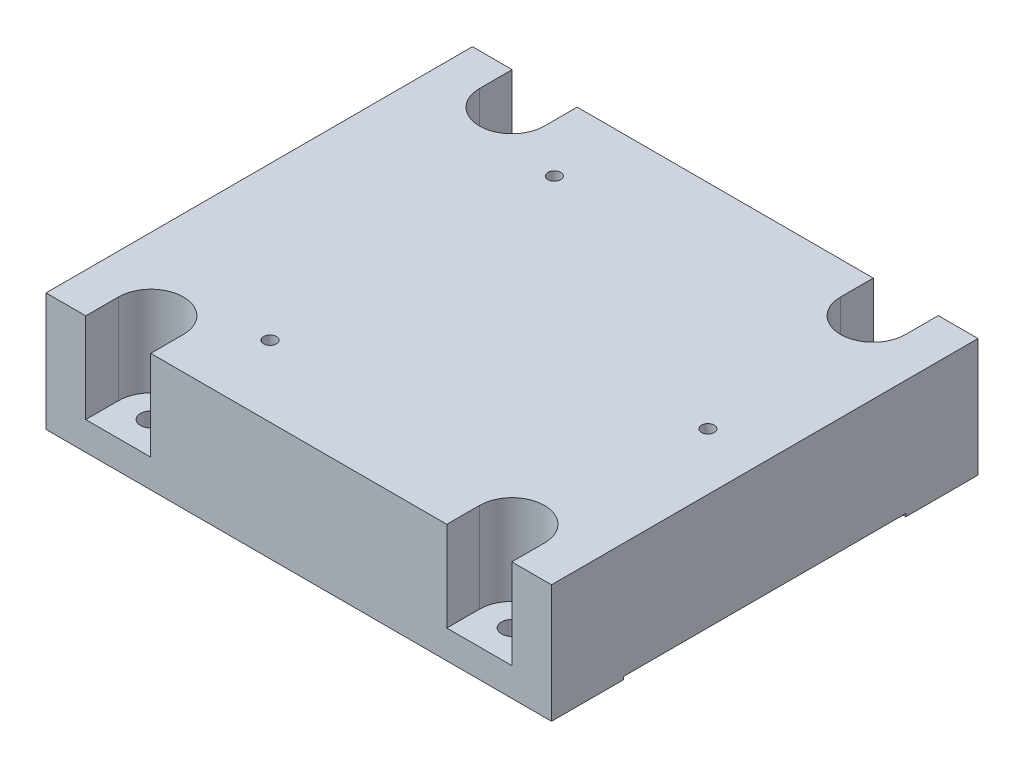
from build123d import *

# Parameters (mm, degrees)
SKETCH1_W                                           = 177.8
SKETCH1_H                                           = 150
BOSS_EXTRUDE1_DEPTH                                 = 41.6
SKETCH2_R                                           = 3.683
CUT_EXTRUDE1_DEPTH                                  = 42.6
CUT_EXTRUDE2_DEPTH                                  = 31.6
CBORE_FOR_M4_HEX_SOCKET_HEAD_CAP_SCREW1_D           = 4.5
CBORE_FOR_M4_HEX_SOCKET_HEAD_CAP_SCREW1_CBORE_D     = 8
CBORE_FOR_M4_HEX_SOCKET_HEAD_CAP_SCREW1_CBORE_DEPTH = 32.6
SKETCH9_W                                           = 177.8
SKETCH9_H                                           = 99.2
CUT_EXTRUDE4_DEPTH                                  = 1


with BuildPart() as part:
    # Sketch1 → Boss-Extrude1 (new body)
    with BuildSketch(Plane(origin=(0, 0, 0), x_dir=(1, 0, 0), z_dir=(0, 1, 0))):
        Rectangle(SKETCH1_W, SKETCH1_H)
    extrude(amount=BOSS_EXTRUDE1_DEPTH)

    # Sketch2 → Cut-Extrude1 (cut, through all)
    with BuildSketch(Plane(origin=(0, 41.6, 0), x_dir=(1, 0, 0), z_dir=(0, 1, 0))):
        with Locations(Location((63.5, -63.5, 0), (0, 0, 270))):  # turned: the seam where the file's is
            Circle(SKETCH2_R)
        with Locations(Location((-63.5, -63.5, 0), (0, 0, 270))):  # turned: the seam where the file's is
            Circle(SKETCH2_R)
    cut_extrude1 = extrude(amount=-CUT_EXTRUDE1_DEPTH, mode=Mode.SUBTRACT)

    # Sketch3 → Cut-Extrude2 (cut)
    with BuildSketch(Plane(origin=(0, 41.6, 0), x_dir=(1, 0, 0), z_dir=(0, 1, 0))):
        with BuildLine():
            Line((-74.93, -63.5), (-74.93, -75))
            Line((-74.93, -75), (-52.07, -75))
            Line((-52.07, -75), (-52.07, -63.5))
            ThreePointArc((-52.07, -63.5), (-63.5, -52.07), (-74.93, -63.5))
        make_face()
        with BuildLine():
            Line((52.07, -63.5), (52.07, -75))
            Line((52.07, -75), (74.93, -75))
            Line((74.93, -75), (74.93, -63.5))
            ThreePointArc((74.93, -63.5), (63.5, -52.07), (52.07, -63.5))
        make_face()
    cut_extrude2 = extrude(amount=-CUT_EXTRUDE2_DEPTH, mode=Mode.SUBTRACT)

    # Mirror1: Cut-Extrude1, Cut-Extrude2 across plane
    add(cut_extrude1.mirror(Plane(origin=(0, 0, 0), x_dir=(1, 0, 0), z_dir=(0, 0, -1))), mode=Mode.SUBTRACT)
    add(cut_extrude2.mirror(Plane(origin=(0, 0, 0), x_dir=(1, 0, 0), z_dir=(0, 0, -1))), mode=Mode.SUBTRACT)

    # CBORE for M4 Hex Socket Head Cap Screw1 (through all)
    with Locations(Plane.XZ):
        with Locations((68.9, 0), (-35.089800026, 50), (-35.089800026, -50)):
            CounterBoreHole(CBORE_FOR_M4_HEX_SOCKET_HEAD_CAP_SCREW1_D / 2, CBORE_FOR_M4_HEX_SOCKET_HEAD_CAP_SCREW1_CBORE_D / 2, CBORE_FOR_M4_HEX_SOCKET_HEAD_CAP_SCREW1_CBORE_DEPTH)

    # Sketch9 → Cut-Extrude4 (cut)
    with BuildSketch(Plane.XZ):
        Rectangle(SKETCH9_W, SKETCH9_H)
    extrude(amount=-CUT_EXTRUDE4_DEPTH, mode=Mode.SUBTRACT)


solid = part.part
